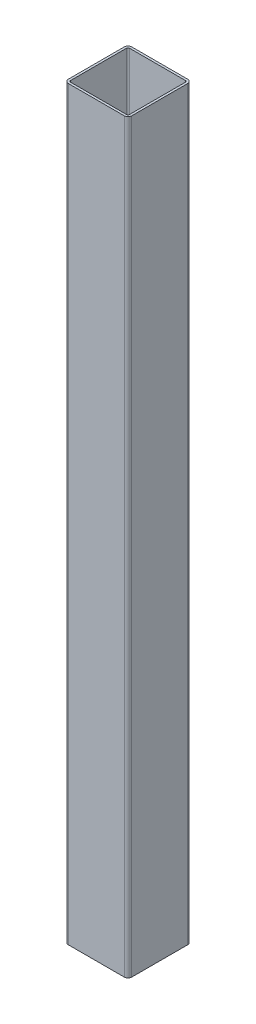
from build123d import *

# Parameters (mm, degrees)
EXTRUDE_1_DEPTH = 1000


with BuildPart() as part:
    # Эскиз1 → Вытянуть-Тонкостенный1 (new body)
    with BuildSketch(Plane(origin=(0, 0, 0), x_dir=(1, 0, 0), z_dir=(0, 1, 0))):
        with BuildLine():
            Line((-42.5, -37.5), (-42.5, 37.5))
            ThreePointArc((-42.5, 37.5), (-41.035533906, 41.035533906), (-37.5, 42.5))
            Line((-37.5, 42.5), (37.5, 42.5))
            ThreePointArc((37.5, 42.5), (41.035533906, 41.035533906), (42.5, 37.5))
            Line((42.5, 37.5), (42.5, -37.5))
            ThreePointArc((42.5, -37.5), (41.035533906, -41.035533906), (37.5, -42.5))
            Line((37.5, -42.5), (-37.5, -42.5))
            ThreePointArc((-37.5, -42.5), (-41.035533906, -41.035533906), (-42.5, -37.5))
        make_face()
        with BuildLine():
            Line((-39.5, -37.5), (-39.5, 37.5))
            ThreePointArc((-39.5, 37.5), (-38.914213562, 38.914213562), (-37.5, 39.5))
            Line((-37.5, 39.5), (37.5, 39.5))
            ThreePointArc((37.5, 39.5), (38.914213562, 38.914213562), (39.5, 37.5))
            Line((39.5, 37.5), (39.5, -37.5))
            ThreePointArc((39.5, -37.5), (38.914213562, -38.914213562), (37.5, -39.5))
            Line((37.5, -39.5), (-37.5, -39.5))
            ThreePointArc((-37.5, -39.5), (-38.914213562, -38.914213562), (-39.5, -37.5))
        make_face(mode=Mode.SUBTRACT)
    extrude(amount=EXTRUDE_1_DEPTH)


solid = part.part
